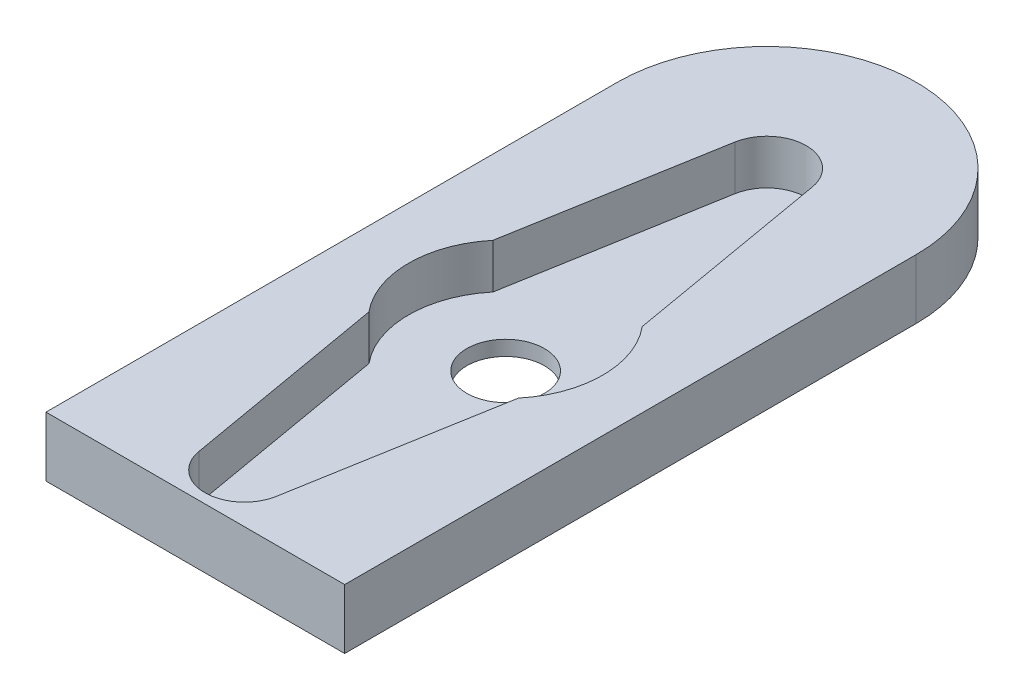
from build123d import *

# Parameters (mm, degrees)
EXTRUDE_6_DEPTH      = 4
CUT_EXTRUDE_12_DEPTH = 3
SKETCH_3_R           = 2.6
CUT_EXTRUDE_13_DEPTH = 4


with BuildPart() as part:
    # 草圖1 → 填料-伸長6 (new body)
    with BuildSketch(Plane(origin=(0, 0, 0), x_dir=(1, 0, 0), z_dir=(0, 1, 0))):
        with BuildLine():
            Line((0, 0), (0, 38.27))
            ThreePointArc((0, 38.27), (10, 48.27), (20, 38.27))
            Line((20, 38.27), (20, 0))
            Line((20, 0), (0, 0))
        make_face()
    extrude(amount=-EXTRUDE_6_DEPTH)

    # 草圖2 → 除料-伸長12 (cut)
    with BuildSketch(Plane(origin=(0, 0, 0), x_dir=(1, 0, 0), z_dir=(0, 1, 0))):
        with BuildLine():
            Line((7.4, 38.722411537), (5, 24.929659817))
            ThreePointArc((5, 24.929659817), (3.500000254, 20.778165453), (4.997678036, 16.625832861))
            Line((4.997678036, 16.625832861), (7.4, 2.833485375))
            ThreePointArc((7.4, 2.833485375), (10, 0.647203241), (12.6, 2.833485375))
            Line((12.6, 2.833485375), (15.002321964, 16.625832861))
            ThreePointArc((15.002321964, 16.625832861), (16.499999746, 20.778165453), (15, 24.929659817))
            Line((15, 24.929659817), (12.6, 38.722411537))
            ThreePointArc((12.6, 38.722411537), (10, 40.909067297), (7.4, 38.722411537))
        make_face()
    extrude(amount=-CUT_EXTRUDE_12_DEPTH, mode=Mode.SUBTRACT)

    # 草圖3 → 除料-伸長13 (cut)
    with BuildSketch(Plane(origin=(0, 0, 0), x_dir=(1, 0, 0), z_dir=(0, 1, 0))):
        with Locations((10, 20.776347886)):
            Circle(SKETCH_3_R)
    extrude(amount=-CUT_EXTRUDE_13_DEPTH, mode=Mode.SUBTRACT)


solid = part.part
